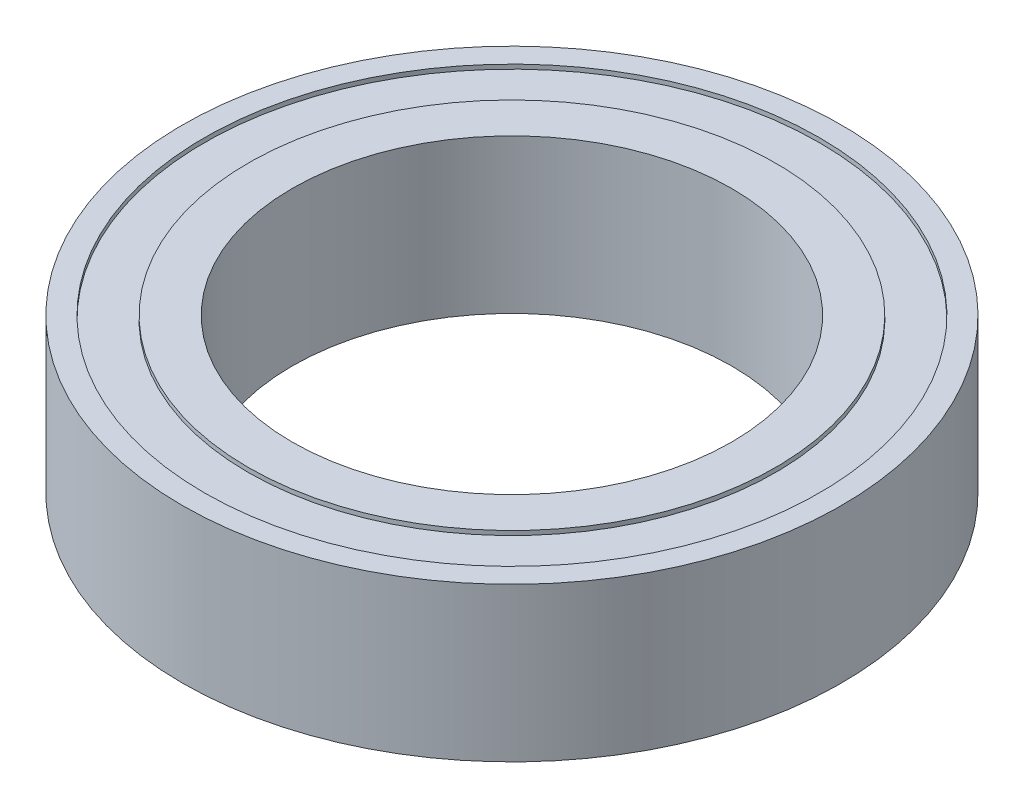
from build123d import *

# Parameters (mm, degrees)
SKETCH1_R           = 7.5
SKETCH1_R_2         = 7
BOSS_EXTRUDE1_DEPTH = 3.5
SKETCH6_R           = 7
SKETCH6_R_2         = 6
BOSS_EXTRUDE4_DEPTH = 3.3
SKETCH7_R           = 6
SKETCH7_R_2         = 5
BOSS_EXTRUDE5_DEPTH = 3.5


with BuildPart() as part:
    # Sketch1 → Boss-Extrude1 (new body)
    with BuildSketch(Plane(origin=(0, 0, 0), x_dir=(1, 0, 0), z_dir=(0, 1, 0))):
        Circle(SKETCH1_R)
        Circle(SKETCH1_R_2, mode=Mode.SUBTRACT)
    extrude(amount=BOSS_EXTRUDE1_DEPTH)

    # Sketch6 → Boss-Extrude4 (add)
    with BuildSketch(Plane(origin=(0, 0.1, 0), x_dir=(1, 0, 0), z_dir=(0, 1, 0))):
        Circle(SKETCH6_R)
        Circle(SKETCH6_R_2, mode=Mode.SUBTRACT)
    extrude(amount=BOSS_EXTRUDE4_DEPTH)

    # Sketch7 → Boss-Extrude5 (add)
    with BuildSketch(Plane(origin=(0, 0, 0), x_dir=(1, 0, 0), z_dir=(0, 1, 0))):
        Circle(SKETCH7_R)
        Circle(SKETCH7_R_2, mode=Mode.SUBTRACT)
    extrude(amount=BOSS_EXTRUDE5_DEPTH)


solid = part.part
